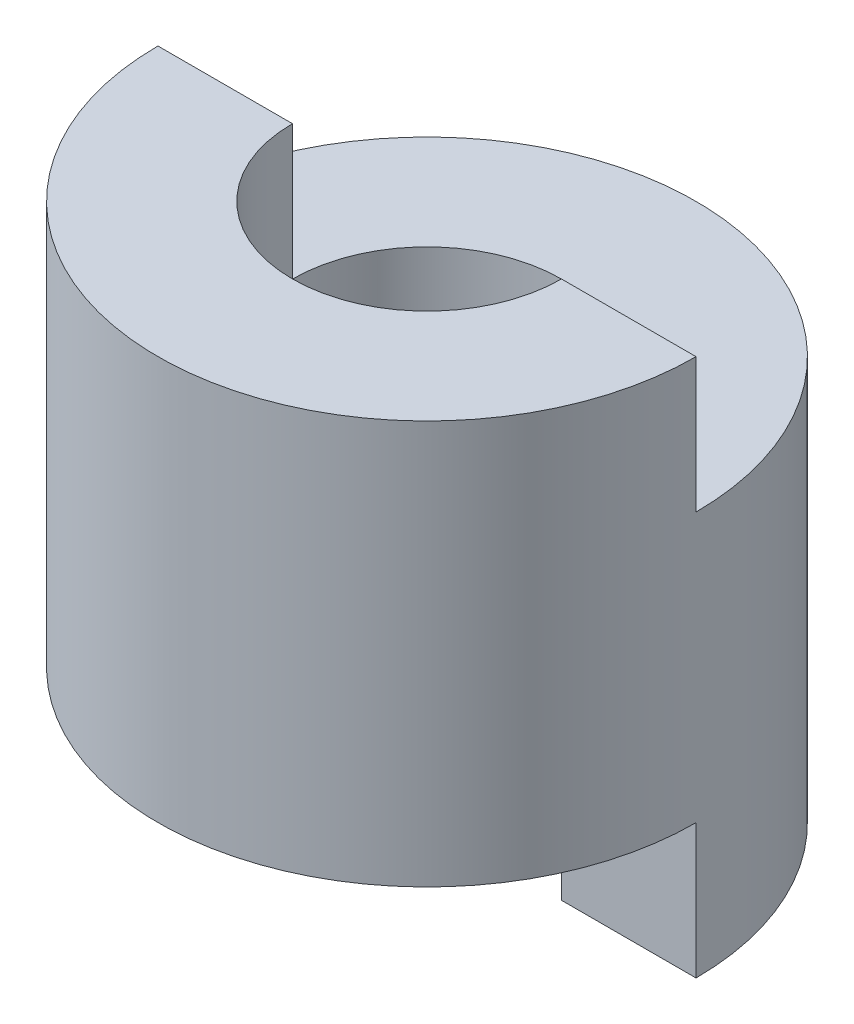
from build123d import *

# Parameters (mm, degrees)
SKETCH1_W          = 10
SKETCH1_H          = 20
SKETCH2_R          = 5
CUT_EXTRUDE1_DEPTH = 20
CUT_EXTRUDE2_DEPTH = 5
CUT_EXTRUDE3_DEPTH = 5


with BuildPart() as part:
    # Sketch1 → Revolve1 (revolve)
    with BuildSketch(Plane.XY):
        with Locations((5, 10)):
            Rectangle(SKETCH1_W, SKETCH1_H)
    revolve(axis=Axis((0, 0, 0), (0, 1, 0)))

    # Sketch2 → Cut-Extrude1 (cut)
    with BuildSketch(Plane(origin=(0, 20, 0), x_dir=(1, 0, 0), z_dir=(0, 1, 0))):
        Circle(SKETCH2_R)
    extrude(amount=-CUT_EXTRUDE1_DEPTH, mode=Mode.SUBTRACT)

    # Sketch3 → Cut-Extrude2 (cut)
    with BuildSketch(Plane(origin=(0, 20, 0), x_dir=(1, 0, 0), z_dir=(0, 1, 0))):
        with BuildLine():
            Line((-10, 0), (-5, 0))
            ThreePointArc((-5, 0), (0, 5), (5, 0))
            Line((5, 0), (10, 0))
            ThreePointArc((10, 0), (0, 10), (-10, 0))
        make_face()
    extrude(amount=-CUT_EXTRUDE2_DEPTH, mode=Mode.SUBTRACT)

    # Sketch4 → Cut-Extrude3 (cut)
    with BuildSketch(Plane.XZ):
        with BuildLine():
            Line((-10, 0), (-5, 0))
            ThreePointArc((-5, 0), (0, 5), (5, 0))
            Line((5, 0), (10, 0))
            ThreePointArc((10, 0), (0, 10), (-10, 0))
        make_face()
    extrude(amount=-CUT_EXTRUDE3_DEPTH, mode=Mode.SUBTRACT)


solid = part.part
